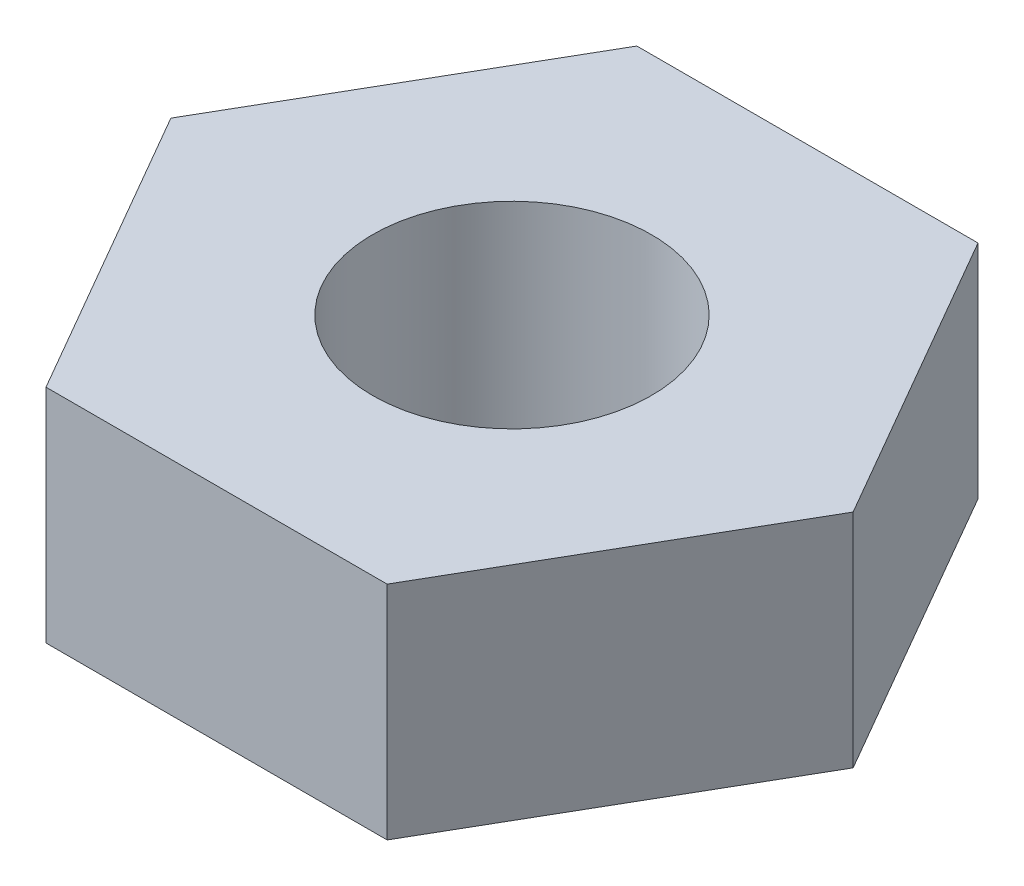
from build123d import *

# Parameters (mm, degrees)
SKETCH1_R           = 1.4986
BOSS_EXTRUDE1_DEPTH = 2.38125


with BuildPart() as part:
    # Sketch1 → Boss-Extrude1 (new body)
    with BuildSketch(Plane(origin=(0, 0, 0), x_dir=(1, 0, 0), z_dir=(0, 1, 0))):
        Polygon((1.833087105, 3.175), (-1.833087105, 3.175), (-3.666174209, 0), (-1.833087105, -3.175), (1.833087105, -3.175), (3.666174209, 0), align=None)
        Circle(SKETCH1_R, mode=Mode.SUBTRACT)
    extrude(amount=BOSS_EXTRUDE1_DEPTH)


solid = part.part
